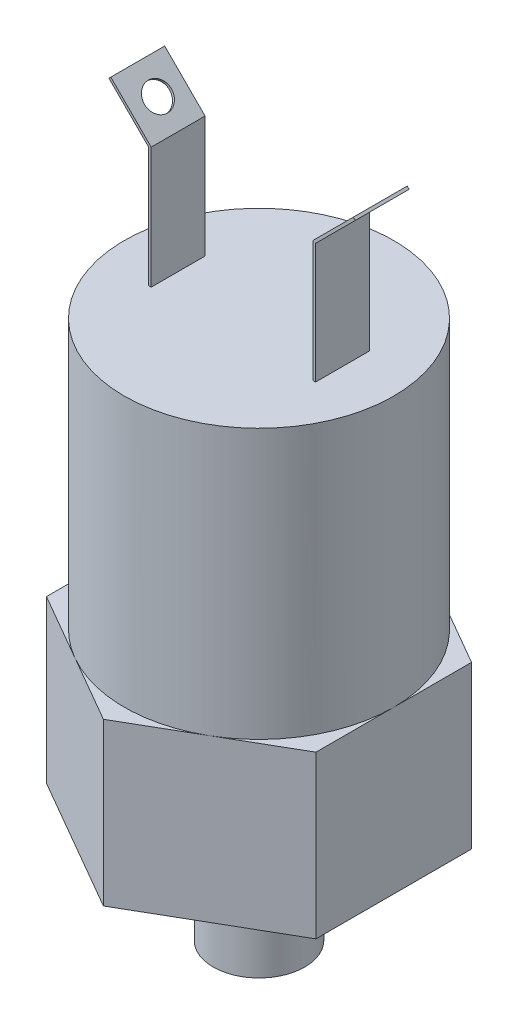
from build123d import *

# Parameters (mm, degrees)
SKETCH1_R           = 4.318
BOSS_EXTRUDE1_DEPTH = 10.16
BOSS_EXTRUDE2_DEPTH = 15.24
SKETCH3_R           = 12.7
BOSS_EXTRUDE3_DEPTH = 25.4
EXTRUDE_THIN1_DEPTH = 2.54
SKETCH5_R           = 1.27
CUT_EXTRUDE1_DEPTH  = 0.254


with BuildPart() as part:
    # Sketch1 → Boss-Extrude1 (new body)
    with BuildSketch(Plane(origin=(0, 0, 0), x_dir=(1, 0, 0), z_dir=(0, 1, 0))):
        Circle(SKETCH1_R)
    extrude(amount=BOSS_EXTRUDE1_DEPTH)

    # Sketch2 → Boss-Extrude2 (add)
    with BuildSketch(Plane(origin=(0, 10.16, 0), x_dir=(1, 0, 0), z_dir=(0, 1, 0))):
        Polygon((0, 14.664696837), (-12.7, 7.332348419), (-12.7, -7.332348419), (0, -14.664696837), (12.7, -7.332348419), (12.7, 7.332348419), align=None)
    extrude(amount=BOSS_EXTRUDE2_DEPTH)

    # Sketch3 → Boss-Extrude3 (add)
    with BuildSketch(Plane(origin=(0, 25.4, 0), x_dir=(1, 0, 0), z_dir=(0, 1, 0))):
        Circle(SKETCH3_R)
    extrude(amount=BOSS_EXTRUDE3_DEPTH)

    # Sketch4 → Extrude-Thin1 (add, symmetric)
    with BuildSketch(Plane.XY):
        Polygon((7.62, 50.8), (7.62, 62.23), (11.43, 66.04), (11.609605122, 65.860394878), (7.874, 62.124789755), (7.874, 50.8), align=None)
    extrude_thin1 = extrude(amount=EXTRUDE_THIN1_DEPTH, both=True)

    # Sketch5 → Cut-Extrude1 (cut)
    with BuildSketch(Plane(origin=(-27.305, 27.305, 0), x_dir=(0, 0, 1), z_dir=(-0.707106781, 0.707106781, 0))):
        with Locations((0, 52.085485502)):
            Circle(SKETCH5_R)
    cut_extrude1 = extrude(amount=-CUT_EXTRUDE1_DEPTH, mode=Mode.SUBTRACT)

    # Mirror1: Extrude-Thin1, Cut-Extrude1 across plane
    add(extrude_thin1.mirror(Plane(origin=(0, 0, 0), x_dir=(0, 0, 1), z_dir=(1, 0, 0))))
    add(cut_extrude1.mirror(Plane(origin=(0, 0, 0), x_dir=(0, 0, 1), z_dir=(1, 0, 0))), mode=Mode.SUBTRACT)


solid = part.part
